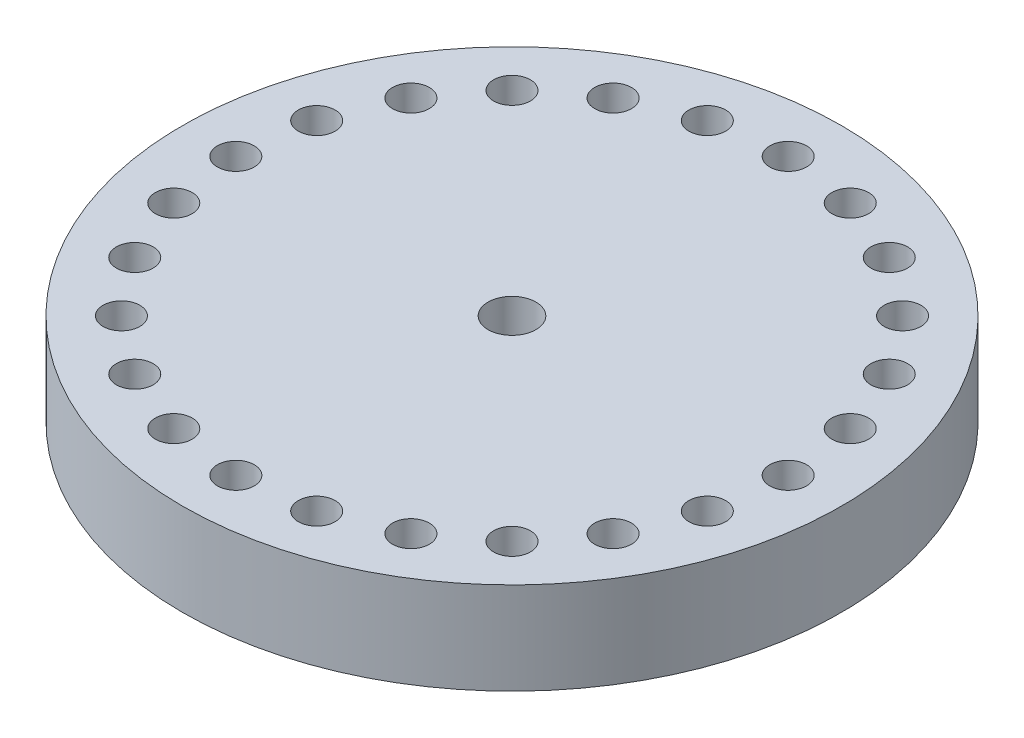
from build123d import *

# Parameters (mm, degrees)
SKETCH1_R                                        = 45.466
BOSS_EXTRUDE1_DEPTH                              = 25.4
SKETCH3_R                                        = 20.32
CUT_EXTRUDE1_DEPTH                               = 12.7
CSK_FOR_1_4_FLAT_HEAD_MACHINE_SCREW1_D           = 6.5278
CSK_FOR_1_4_FLAT_HEAD_MACHINE_SCREW1_DEPTH       = 25.4
CSK_FOR_1_4_FLAT_HEAD_MACHINE_SCREW1_CSINK_D     = 12.8778
CSK_FOR_1_4_FLAT_HEAD_MACHINE_SCREW1_CSINK_ANGLE = 82
CSK_FOR_1_4_FLAT_HEAD_MACHINE_SCREW1_TIP         = 1.961148974
SKETCH8_R                                        = 46.955588052
CUT_EXTRUDE2_DEPTH                               = 12.7
SKETCH4_R                                        = 1.778
CUT_EXTRUDE3_DEPTH                               = 13.7
SKETCH9_R                                        = 2.54
CUT_EXTRUDE4_DEPTH                               = 5.08
CIRPATTERN1_COUNT                                = 24
SKETCH10_R                                       = 22.834776664
BOSS_EXTRUDE2_DEPTH                              = 5.08
SKETCH11_R                                       = 3.302
CUT_EXTRUDE5_DEPTH                               = 13.7


with BuildPart() as part:
    # Sketch1 → Boss-Extrude1 (new body)
    with BuildSketch(Plane(origin=(0, 0, 0), x_dir=(1, 0, 0), z_dir=(0, 1, 0))):
        Circle(SKETCH1_R)
    extrude(amount=BOSS_EXTRUDE1_DEPTH)

    # Sketch3 → Cut-Extrude1 (cut)
    with BuildSketch(Plane.XZ):
        Circle(SKETCH3_R)
    extrude(amount=-CUT_EXTRUDE1_DEPTH, mode=Mode.SUBTRACT)

    # CSK for 1/4 Flat Head Machine Screw1
    with Locations(Plane(origin=(0, 25.4, 0), x_dir=(1, 0, 0), z_dir=(0, 1, 0))):
        with Locations((0, 0)):
            CounterSinkHole(CSK_FOR_1_4_FLAT_HEAD_MACHINE_SCREW1_D / 2, CSK_FOR_1_4_FLAT_HEAD_MACHINE_SCREW1_CSINK_D / 2, depth=CSK_FOR_1_4_FLAT_HEAD_MACHINE_SCREW1_DEPTH, counter_sink_angle=CSK_FOR_1_4_FLAT_HEAD_MACHINE_SCREW1_CSINK_ANGLE)
            with Locations((0, 0, -(CSK_FOR_1_4_FLAT_HEAD_MACHINE_SCREW1_DEPTH + CSK_FOR_1_4_FLAT_HEAD_MACHINE_SCREW1_TIP / 2))):  # 118° drill point
                Cone(0, CSK_FOR_1_4_FLAT_HEAD_MACHINE_SCREW1_D / 2, CSK_FOR_1_4_FLAT_HEAD_MACHINE_SCREW1_TIP, mode=Mode.SUBTRACT)

    # Sketch8 → Cut-Extrude2 (cut)
    with BuildSketch(Plane(origin=(0, 25.4, 0), x_dir=(1, 0, 0), z_dir=(0, 1, 0))):
        Circle(SKETCH8_R)
    extrude(amount=-CUT_EXTRUDE2_DEPTH, mode=Mode.SUBTRACT)

    # Sketch4 → Cut-Extrude3 (cut, through all)
    with BuildSketch(Plane.XZ):
        with Locations((0, 38.1)):
            Circle(SKETCH4_R)
    cut_extrude3 = extrude(amount=-CUT_EXTRUDE3_DEPTH, mode=Mode.SUBTRACT)

    # Sketch9 → Cut-Extrude4 (cut)
    with BuildSketch(Plane(origin=(0, 12.7, 0), x_dir=(1, 0, 0), z_dir=(0, 1, 0))):
        with Locations((0, -38.1)):
            Circle(SKETCH9_R)
    cut_extrude4 = extrude(amount=-CUT_EXTRUDE4_DEPTH, mode=Mode.SUBTRACT)

    # CirPattern1: Cut-Extrude3, Cut-Extrude4 ×24 about axis
    cirpattern1_axis = Axis((0, 0, 0), (0, 1, 0))
    for i in range(1, CIRPATTERN1_COUNT):
        add(cut_extrude3.rotate(cirpattern1_axis, i * 360 / CIRPATTERN1_COUNT), mode=Mode.SUBTRACT)
        add(cut_extrude4.rotate(cirpattern1_axis, i * 360 / CIRPATTERN1_COUNT), mode=Mode.SUBTRACT)

    # Sketch10 → Boss-Extrude2 (add)
    with BuildSketch(Plane(origin=(0, 12.7, 0), x_dir=(1, 0, 0), z_dir=(0, 1, 0))):
        Circle(SKETCH10_R)
    extrude(amount=-BOSS_EXTRUDE2_DEPTH)

    # Sketch11 → Cut-Extrude5 (cut, through all)
    with BuildSketch(Plane(origin=(0, 12.7, 0), x_dir=(1, 0, 0), z_dir=(0, 1, 0))):
        Circle(SKETCH11_R)
    extrude(amount=-CUT_EXTRUDE5_DEPTH, mode=Mode.SUBTRACT)


solid = part.part
